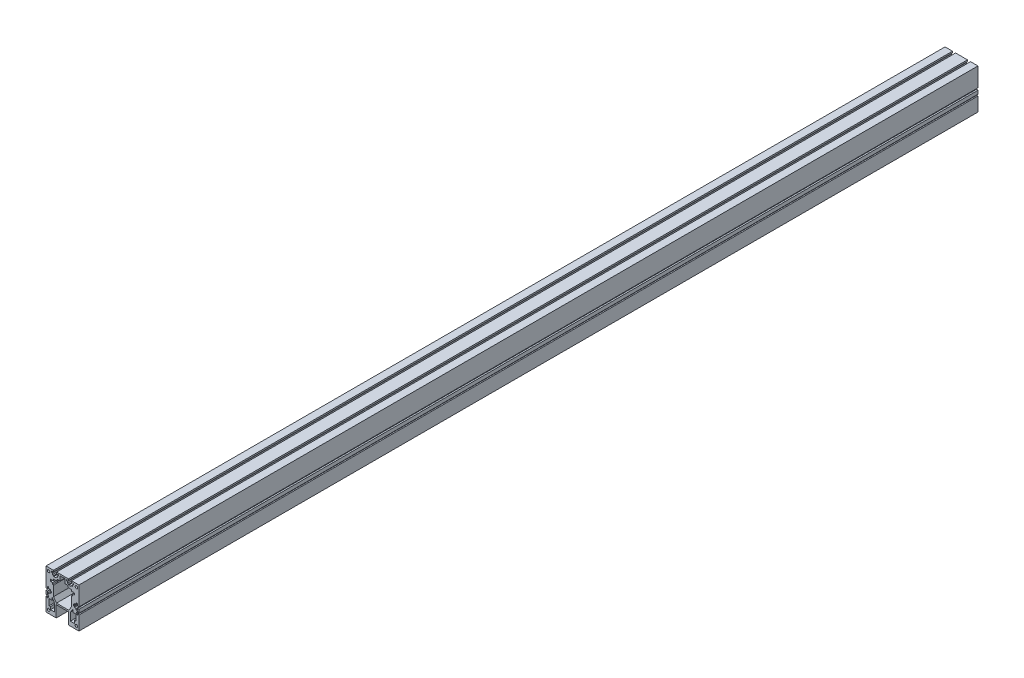
from build123d import *

# Parameters (mm, degrees)
SKETCH_2_R      = 2.5
EXTRUDE_1_DEPTH = 1800


with BuildPart() as part:
    # 草图2 → 凸台-拉伸1 (new body)
    with BuildSketch(Plane.XY):
        Polygon((-18.1, 37), (-18.1, 40), (-33, 40), (-33, 2.049564589), (-30, 2.049564589), (-30, 6.348214799), (-27.5, 6.348214799), (-27.5, 3.593219783), (-24, 3.593219783), (-24, 1.376590931), (-22.4, 1.376590931), (-22.4, -1.376590931), (-24, -1.376590931), (-24, -3.593219783), (-27.5, -3.593219783), (-27.5, -6.348214799), (-30, -6.348214799), (-30, -2.049564589), (-33, -2.049564589), (-33, -9.06837916), (-30.729793093, -9.06837916), (-30.729793093, -7.473013176), (-29.144133649, -7.473013176), (-29.144133649, -9.06837916), (-27.8, -9.06837916), (-27.8, -10.56837916), (-27.8, -12.06837916), (-29.144133649, -12.06837916), (-29.144133649, -13.663745144), (-30.729793093, -13.663745144), (-30.729793093, -12.06837916), (-33, -12.06837916), (-33, -40), (-12.5, -40), (-12.5, -17), (12.5, -17), (12.5, -40), (33, -40), (33, -12.06837916), (30.729793093, -12.06837916), (30.729793093, -13.663745144), (29.144133649, -13.663745144), (29.144133649, -12.06837916), (27.8, -12.06837916), (27.8, -10.56837916), (27.8, -9.06837916), (29.144133649, -9.06837916), (29.144133649, -7.473013176), (30.729793093, -7.473013176), (30.729793093, -9.06837916), (33, -9.06837916), (33, -2.049564589), (30, -2.049564589), (30, -6.348214799), (27.5, -6.348214799), (27.5, -3.593219783), (24, -3.593219783), (24, -1.376590931), (22.4, -1.376590931), (22.4, 1.376590931), (24, 1.376590931), (24, 3.593219783), (27.5, 3.593219783), (27.5, 6.348214799), (30, 6.348214799), (30, 2.049564589), (33, 2.049564589), (33, 40), (18.1, 40), (18.1, 37), (22.1, 37), (22.1, 34.5), (20.1, 34.5), (20.1, 31), (17.5, 31), (17.5, 29.4), (12.5, 29.4), (12.5, 31), (9.9, 31), (9.9, 34.5), (7.9, 34.5), (7.9, 37), (11.9, 37), (11.9, 40), (-11.9, 40), (-11.9, 37), (-7.9, 37), (-7.9, 34.5), (-9.9, 34.5), (-9.9, 31), (-12.5, 31), (-12.5, 29.4), (-17.5, 29.4), (-17.5, 31), (-20.1, 31), (-20.1, 34.5), (-22.1, 34.5), (-22.1, 37), align=None)
        with Locations((-27.8, -33.5)):
            Circle(SKETCH_2_R, mode=Mode.SUBTRACT)
        Polygon((-20.943121928, -13.45406673), (-20.943121928, -8.11004262), (-15.8, -15.86033199), (-15.8, -31.360910729), (-24, -31.360910729), (-24, -25.86703472), (-26.644243735, -25.86703472), (-26.644243735, -13.45406673), align=None, mode=Mode.SUBTRACT)
        with Locations((27.8, -33.5)):
            Circle(SKETCH_2_R, mode=Mode.SUBTRACT)
        Polygon((24, -25.86703472), (24, -31.360910729), (15.8, -31.360910729), (15.8, -15.86033199), (20.943121928, -8.11004262), (20.943121928, -13.45406673), (26.644243735, -13.45406673), (26.644243735, -25.86703472), align=None, mode=Mode.SUBTRACT)
        with Locations((-27.8, 33.5)):
            Circle(SKETCH_2_R, mode=Mode.SUBTRACT)
        Polygon((-24.000227571, 17.552802839), (-24.000227571, 21.788095294), (-17.932238887, 21.788095294), (-17.932238887, 24.712463894), (-10.638888278, 24.712463894), (-10.638888278, 28.169211595), (-4.9, 28.169211595), (-4.9, 37), (4.9, 37), (4.9, 28.169211595), (10.638888278, 28.169211595), (10.638888278, 24.712463894), (17.932238887, 24.712463894), (17.932238887, 21.788095294), (24.000227571, 21.788095294), (24.000227571, 17.552802839), (20.143121928, 17.552802839), (20.143121928, 14.174652905), (17.932238887, 14.174652905), (17.932238887, -5.752091446), (12.045824189, -14), (0, -14), (-12.045824189, -14), (-17.932238887, -5.752091446), (-17.932238887, 14.174652905), (-20.143121928, 14.174652905), (-20.143121928, 17.552802839), align=None, mode=Mode.SUBTRACT)
        with Locations((27.8, 33.5)):
            Circle(SKETCH_2_R, mode=Mode.SUBTRACT)
    extrude(amount=EXTRUDE_1_DEPTH)


solid = part.part
